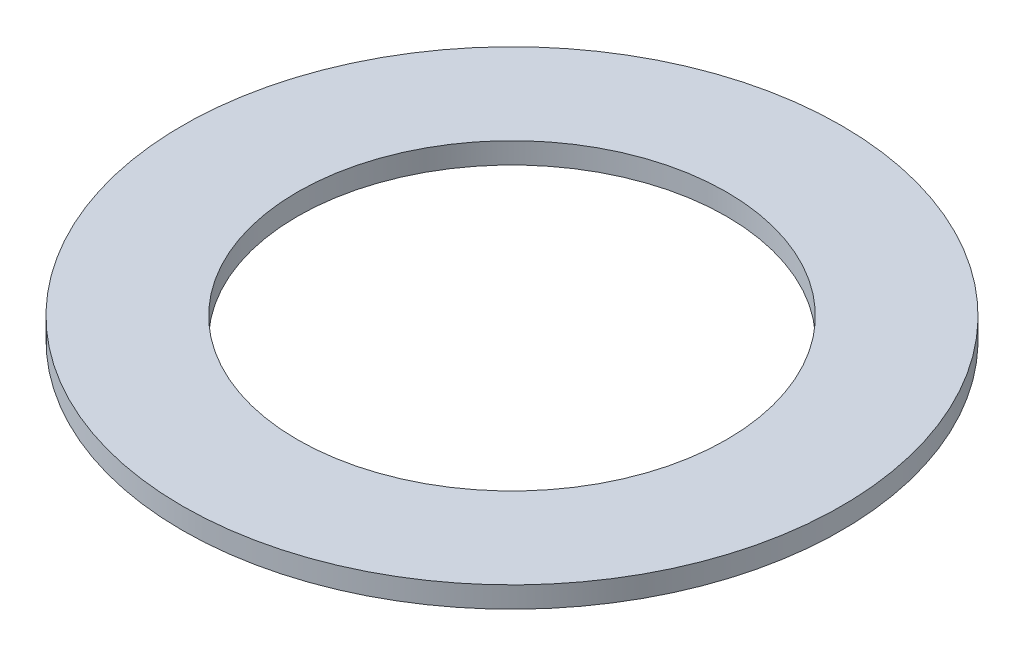
from build123d import *

# Parameters (mm, degrees)
SKETCH1_W = 4.4323
SKETCH1_H = 0.8128


with BuildPart() as part:
    # Sketch1 → Revolve1 (revolve)
    with BuildSketch(Plane(origin=(0, 0, 0), x_dir=(-1, 0, 0), z_dir=(0, 0, -1))):
        with Locations((-10.48385, 0.4064)):
            Rectangle(SKETCH1_W, SKETCH1_H)
    revolve(axis=Axis((0, 0, 0), (0, 1, 0)))


solid = part.part
